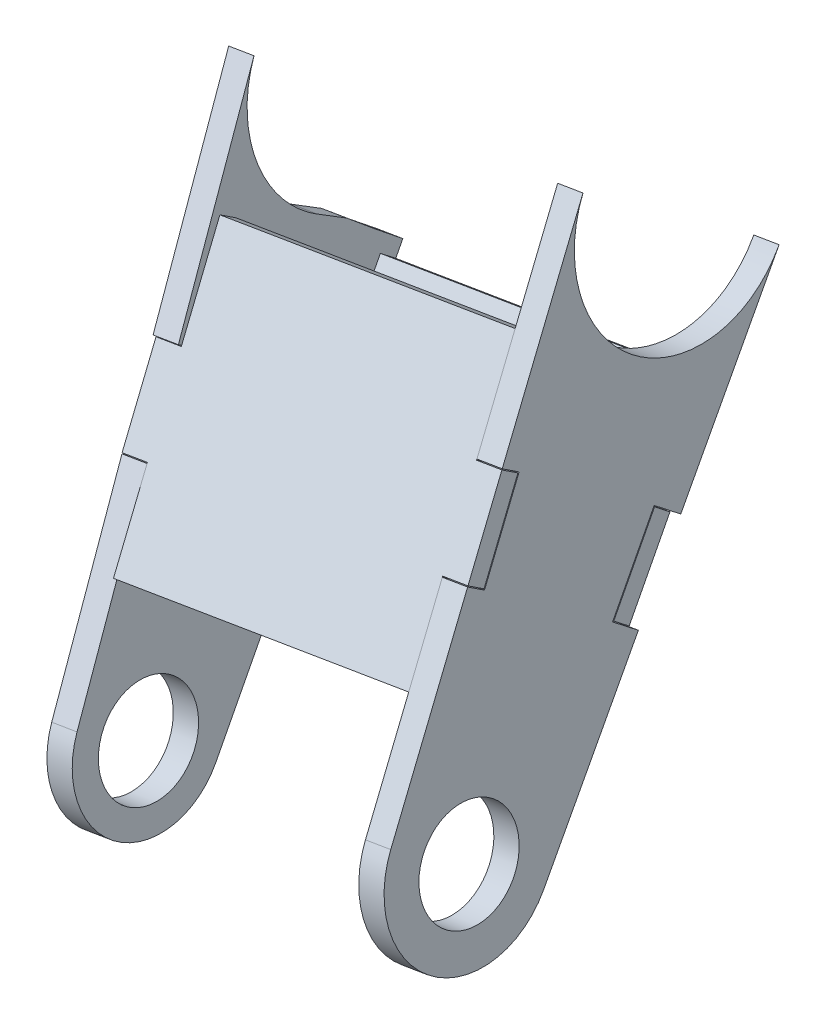
from build123d import *

# Parameters (mm, degrees)
SZKIC1_R                    = 5.75
DODANIE_WYCI_GNI_CIE1_DEPTH = 3
WYTNIJ_WYCI_GNI_CIE2_DEPTH  = 4
SZKIC3_R                    = 5.75
DODANIE_WYCI_GNI_CIE2_DEPTH = 3
DODANIE_WYCI_GNI_CIE3_DEPTH = 2
WYTNIJ_WYCI_GNI_CIE5_DEPTH  = 52.458233786
DODANIE_WYCI_GNI_CIE4_DEPTH = 2
WYTNIJ_WYCI_GNI_CIE6_DEPTH  = 52.326394369


with BuildPart() as part:
    # Szkic1 → Dodanie-wyciągnięcie1 (new body)
    with BuildSketch(Plane(origin=(1353.926196645, 228.277019177, 3.474323827), x_dir=(-0.002495171, -0.000420695, 0.999996799), z_dir=(-0.986079268, -0.166256652, -0.002530388))):
        with BuildLine():
            Line((441.253729445, -472.717830488), (412.321307972, -422.369080805))
            add(Edge.make_bspline(
                [(412.321307972, -422.369080805), (419.534612329, -434.921810131), (409.382942082, -443.035336139), (398.958819921, -440.887627989), (396.244969441, -440.328486537), (393.549490929, -438.853317877), (391.545812295, -436.223029822)],
                knots=[0.155088839, 0.155088839, 0.155088839, 0.155088839, 0.5, 0.5, 0.5, 0.636085355, 0.636085355, 0.636085355, 0.636085355], degree=3, weights=[0.572065028, 0.397473461, 0.540118452, 1, 0.818552861, 0.686490318, 0.603812372]))
            Line((391.545812295, -436.223029822), (426.706645918, -482.379693415))
            ThreePointArc((426.706645918, -482.379693415), (438.50818535, -484.366200864), (441.253729445, -472.717830488))
        make_face()
        with Locations((433.667120391, -477.077401919)):
            Circle(SZKIC1_R, mode=Mode.SUBTRACT)
    extrude(amount=DODANIE_WYCI_GNI_CIE1_DEPTH)

    # Szkic2 → Wytnij-wyciągnięcie2 (cut)
    with BuildSketch(Plane(origin=(1353.926196645, 228.277019177, 3.474323827), x_dir=(-0.002495171, -0.000420695, 0.999996799), z_dir=(-0.986079268, -0.166256652, -0.002530388))):
        with BuildLine():
            Line((404.65211173, -441.281083771), (407.821394229, -439.412393836))
            add(Edge.make_bspline(
                [(407.821394229, -439.412393836), (404.88822276, -441.141866675), (401.74377418, -441.461419131), (398.958819921, -440.887627989), (396.244969441, -440.328486537), (393.549490929, -438.853317877), (391.545812295, -436.223029822)],
                knots=[0.36100992, 0.36100992, 0.36100992, 0.36100992, 0.5, 0.5, 0.5, 0.636085355, 0.636085355, 0.636085355, 0.636085355], degree=3, weights=[0.598585618, 0.680875099, 0.814679893, 1, 0.818552861, 0.686490318, 0.603812372]))
            Line((391.545812295, -436.223029822), (398.913248998, -445.894481333))
            add(Edge.make_bspline(
                [(404.65211173, -441.281083771), (402.813382058, -442.825248985), (400.897379873, -444.366955046), (398.913248998, -445.894481333)],
                knots=[0, 0, 0, 0, 0.049966966, 0.049966966, 0.049966966, 0.049966966], degree=3, weights=[1, 0.976581917, 0.955504095, 0.936766535]))
        make_face()
    extrude(amount=WYTNIJ_WYCI_GNI_CIE2_DEPTH, mode=Mode.SUBTRACT)


with BuildPart() as body_2:
    # Szkic3 → Dodanie-wyciągnięcie2 (new body)
    with BuildSketch(Plane(origin=(1388.438971028, 234.096001984, 3.562887409), x_dir=(-0.002495171, -0.000420695, 0.999996799), z_dir=(-0.986079268, -0.166256652, -0.002530388))):
        with BuildLine():
            ThreePointArc((425.97506823, -483.068631638), (439.276403639, -485.052265017), (441.905846435, -471.8633926))
            Line((441.905846435, -471.8633926), (411.615109292, -424.000592643))
            add(Edge.make_bspline(
                [(411.615109292, -424.000592643), (419.595034213, -436.609779022), (409.302289126, -445.196085213), (398.528479374, -442.976330047), (395.854111239, -442.425323243), (393.195756664, -440.983753213), (391.197443428, -438.418148092)],
                knots=[0.148934404, 0.148934404, 0.148934404, 0.148934404, 0.5, 0.5, 0.5, 0.634460468, 0.634460468, 0.634460468, 0.634460468], degree=3, weights=[0.581714038, 0.392483884, 0.531912538, 1, 0.820719376, 0.689651066, 0.606795068]))
            Line((391.197443428, -438.418148092), (425.97506823, -483.068631638))
        make_face()
        with Locations((433.667120391, -477.077401919)):
            Circle(SZKIC3_R, mode=Mode.SUBTRACT)
    extrude(amount=-DODANIE_WYCI_GNI_CIE2_DEPTH)


with BuildPart() as body_3:
    # Szkic5 → Dodanie-wyciągnięcie3 (new body)
    with BuildSketch(Plane(origin=(-11.019604992, 63.800963274, 102.304268594), x_dir=(-0.139152569, 0.833462201, -0.534768474), z_dir=(0.091017799, -0.526971996, -0.844994838))):
        Polygon((-622.291479281, 1373.039917254), (-612.291479281, 1373.039917254), (-612.291479281, 1370.039917254), (-602.291479281, 1370.039917254), (-602.291479281, 1373.039917254), (-590.934128354, 1373.039917254), (-590.934128354, 1408.039917254), (-602.291479281, 1408.039917254), (-602.291479281, 1411.039917254), (-612.291479281, 1411.039917254), (-612.291479281, 1408.039917254), (-622.291479281, 1408.039917254), align=None)
    extrude(amount=DODANIE_WYCI_GNI_CIE3_DEPTH)


with BuildPart() as wytnij_wyci_gni_cie5_tool:
    # Szkic6 → Wytnij-wyciągnięcie5 (new body, through all)
    with BuildSketch(Plane(origin=(1391.397208832, 234.594771939, 3.570478573), x_dir=(0.002495171, 0.000420695, -0.999996799), z_dir=(0.986079268, 0.166256652, 0.002530388))):
        Polygon((-429.877801464, -452.670721233), (-428.01880687, -453.847215644), (-422.564150967, -445.228240705), (-424.423145562, -444.051746295), (-425.099143596, -443.623930146), (-430.553799499, -452.242905084), align=None)
    extrude(amount=-WYTNIJ_WYCI_GNI_CIE5_DEPTH)


with BuildPart() as body_2_1:
    add(body_2.part)

    # Wytnij-wyciągnięcie5: cut by wytnij_wyci_gni_cie5_tool
    add(wytnij_wyci_gni_cie5_tool.part, mode=Mode.SUBTRACT)


with BuildPart() as part_1:
    add(part.part)

    # Wytnij-wyciągnięcie5: cut by wytnij_wyci_gni_cie5_tool
    add(wytnij_wyci_gni_cie5_tool.part, mode=Mode.SUBTRACT)


with BuildPart() as body_4:
    # Szkic8 → Dodanie-wyciągnięcie4 (new body)
    with BuildSketch(Plane(origin=(-4.841506853, 28.144729202, 37.488754103), x_dir=(-0.994708897, -0.061327404, -0.082420631), z_dir=(0.102732757, -0.597207796, -0.79548025))):
        Polygon((-1476.126488844, -418.541211572), (-1474.62501424, -407.254986635), (-1439.930687938, -411.870582206), (-1441.432162542, -423.156807143), (-1438.458363145, -423.55242962), (-1439.777104737, -433.465094278), (-1442.750904134, -433.0694718), (-1444.069645726, -442.982136458), (-1478.763972027, -438.366540887), (-1477.445230435, -428.453876229), (-1480.419029833, -428.058253752), (-1479.100288241, -418.145589094), align=None)
    extrude(amount=-DODANIE_WYCI_GNI_CIE4_DEPTH)


with BuildPart() as wytnij_wyci_gni_cie6_tool:
    # Szkic9 → Wytnij-wyciągnięcie6 (new body, through all)
    with BuildSketch(Plane(origin=(1350.967958841, 227.778249223, 3.466732662), x_dir=(-0.002495171, -0.000420695, 0.999996799), z_dir=(-0.986079268, -0.166256652, -0.002530388))):
        Polygon((412.901737365, -464.422605683), (414.651799518, -463.089458106), (408.470842573, -454.975533578), (406.72078042, -456.308681154), (405.288911386, -457.399438262), (411.46986833, -465.513362791), align=None)
    extrude(amount=-WYTNIJ_WYCI_GNI_CIE6_DEPTH)


with BuildPart() as body_2_2:
    add(body_2_1.part)

    # Wytnij-wyciągnięcie6: cut by wytnij_wyci_gni_cie6_tool
    add(wytnij_wyci_gni_cie6_tool.part, mode=Mode.SUBTRACT)


with BuildPart() as part_2:
    add(part_1.part)

    # Wytnij-wyciągnięcie6: cut by wytnij_wyci_gni_cie6_tool
    add(wytnij_wyci_gni_cie6_tool.part, mode=Mode.SUBTRACT)


solid = Compound([body_3.part, body_4.part, body_2_2.part, part_2.part])
